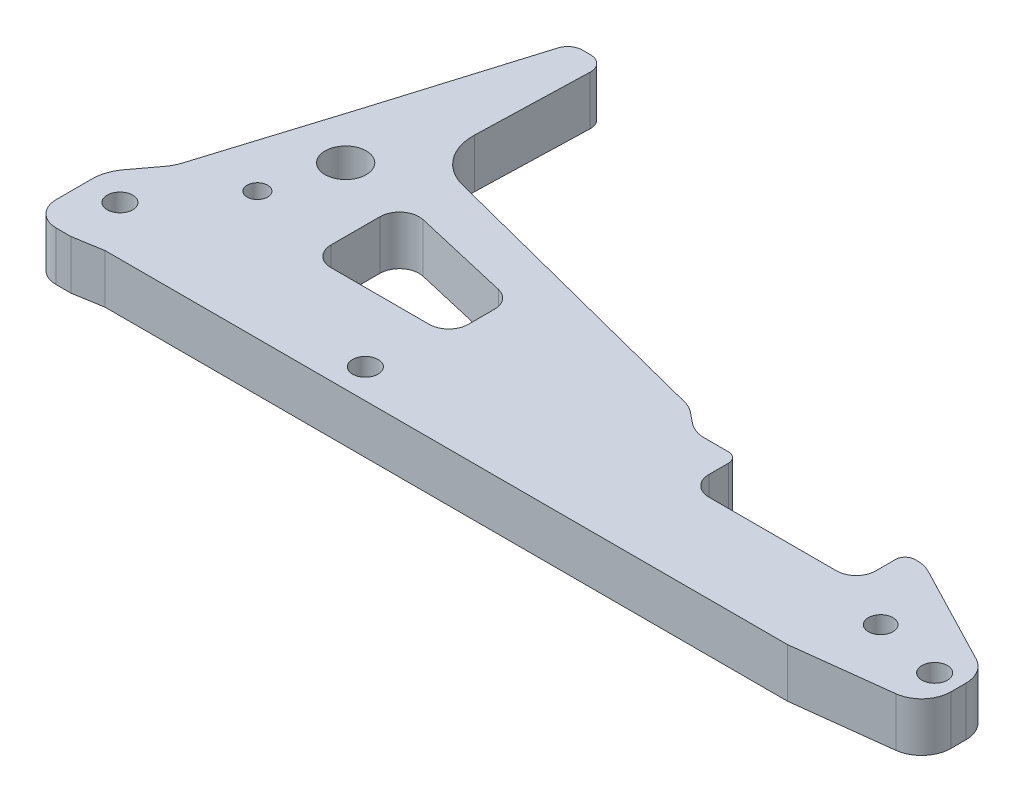
from build123d import *

# Parameters (mm, degrees)
SKETCH1_R           = 2.6
SKETCH1_R_2         = 2.1
SKETCH1_R_3         = 4.2
SKETCH1_R_4         = 2.5
BOSS_EXTRUDE1_DEPTH = 10
FILLET2_R           = 6
FILLET3_R           = 3
CUT_EXTRUDE1_DEPTH  = 11
SKETCH7_R           = 2.6
CUT_EXTRUDE4_DEPTH  = 11
FILLET8_R           = 5
FILLET9_R           = 4
SKETCH10_W          = 34
SKETCH10_H          = 10
CUT_EXTRUDE6_DEPTH  = 11
FILLET10_R          = 4
CUT_EXTRUDE7_DEPTH  = 5
FILLET14_R          = 6
FILLET15_R          = 2
FILLET16_R          = 10
FILLET17_R          = 8
FILLET18_R          = 4


with BuildPart() as part:
    # Sketch1 → Boss-Extrude1 (new body)
    with BuildSketch(Plane(origin=(0, 0, 0), x_dir=(1, 0, 0), z_dir=(0, 1, 0))):
        Polygon((164, 15), (139, 28), (92, 28), (87, 32), (17, 50), (18, 84), (11, 84), (1, 51), (-8, 22), (-14, 14), (-14, 2), (-14, -1), (-6, -1), (0, 0), (139, 0), (164, 3), align=None)
        with Locations((-7, 10)):
            Circle(SKETCH1_R, mode=Mode.SUBTRACT)
        with Locations((159, 10)):
            Circle(SKETCH1_R, mode=Mode.SUBTRACT)
        with Locations((5, 26)):
            Circle(SKETCH1_R_2, mode=Mode.SUBTRACT)
        with Locations((9, 40)):
            Circle(SKETCH1_R_3, mode=Mode.SUBTRACT)
        with Locations((145, 13)):
            Circle(SKETCH1_R_4, mode=Mode.SUBTRACT)
    extrude(amount=BOSS_EXTRUDE1_DEPTH)

    # Fillet2
    fillet2_edges = [part.edges().sort_by_distance(p)[0] for p in [
        (139, 5, -28),
        (164, 5, -15),
        (164, 5, -3),
    ]]
    fillet(fillet2_edges, radius=FILLET2_R)

    # Fillet3
    fillet3_edges = [part.edges().sort_by_distance(p)[0] for p in [
        (11, 5, -84),
        (18, 5, -84),
    ]]
    fillet(fillet3_edges, radius=FILLET3_R)

    # Sketch4 → Cut-Extrude1 (cut, through all)
    with BuildSketch(Plane(origin=(0, 10, 0), x_dir=(1, 0, 0), z_dir=(0, 1, 0))):
        Polygon((22, 39), (22, 20), (50, 20), (50, 32.5), align=None)
    extrude(amount=-CUT_EXTRUDE1_DEPTH, mode=Mode.SUBTRACT)

    # Sketch7 → Cut-Extrude4 (cut, through all)
    with BuildSketch(Plane(origin=(0, 10, 0), x_dir=(1, 0, 0), z_dir=(0, 1, 0))):
        with Locations((47, 6)):
            Circle(SKETCH7_R)
    extrude(amount=-CUT_EXTRUDE4_DEPTH, mode=Mode.SUBTRACT)

    # Fillet8
    fillet8_edges = [part.edges().sort_by_distance(p)[0] for p in [
        (-14, 5, 1),
    ]]
    fillet(fillet8_edges, radius=FILLET8_R)

    # Fillet9
    fillet9_edges = [part.edges().sort_by_distance(p)[0] for p in [
        (22, 5, -39),
        (50, 5, -32.5),
        (50, 5, -20),
        (22, 5, -20),
    ]]
    fillet(fillet9_edges, radius=FILLET9_R)

    # Sketch10 → Cut-Extrude6 (cut, through all)
    with BuildSketch(Plane(origin=(0, 10, 0), x_dir=(1, 0, 0), z_dir=(0, 1, 0))):
        with Locations((118, 23)):
            Rectangle(SKETCH10_W, SKETCH10_H)
    extrude(amount=-CUT_EXTRUDE6_DEPTH, mode=Mode.SUBTRACT)

    # Fillet10
    fillet10_edges = [part.edges().sort_by_distance(p)[0] for p in [
        (135, 5, -18),
        (101, 5, -18),
    ]]
    fillet(fillet10_edges, radius=FILLET10_R)

    # Sketch12 → Cut-Extrude7 (cut)
    with BuildSketch(Plane(origin=(0, 0, 0), x_dir=(1, 0, 0), z_dir=(0, 1, 0))):
        Polygon((58, 37), (83, 31.034746853), (89, 26.034746853), (89, 14), (58, 14), align=None)
    extrude(amount=CUT_EXTRUDE7_DEPTH, mode=Mode.SUBTRACT)

    # Fillet14
    fillet14_edges = [part.edges().sort_by_distance(p)[0] for p in [
        (87, 5, -32),
        (92, 5, -28),
    ]]
    fillet(fillet14_edges, radius=FILLET14_R)

    # Fillet15
    fillet15_edges = [part.edges().sort_by_distance(p)[0] for p in [
        (101, 5, -28),
        (135, 5, -28),
    ]]
    fillet(fillet15_edges, radius=FILLET15_R)

    # Fillet16
    fillet16_edges = [part.edges().sort_by_distance(p)[0] for p in [
        (17, 5, -50),
    ]]
    fillet(fillet16_edges, radius=FILLET16_R)

    # Fillet17
    fillet17_edges = [part.edges().sort_by_distance(p)[0] for p in [
        (-14, 5, -14),
        (-8, 5, -22),
    ]]
    fillet(fillet17_edges, radius=FILLET17_R)

    # Fillet18
    fillet18_edges = [part.edges().sort_by_distance(p)[0] for p in [
        (58, 2.5, -37),
        (58, 2.5, -14),
        (89, 2.5, -14),
        (89, 2.5, -26.034746853),
        (83, 2.5, -31.034746853),
    ]]
    fillet(fillet18_edges, radius=FILLET18_R)


solid = part.part
